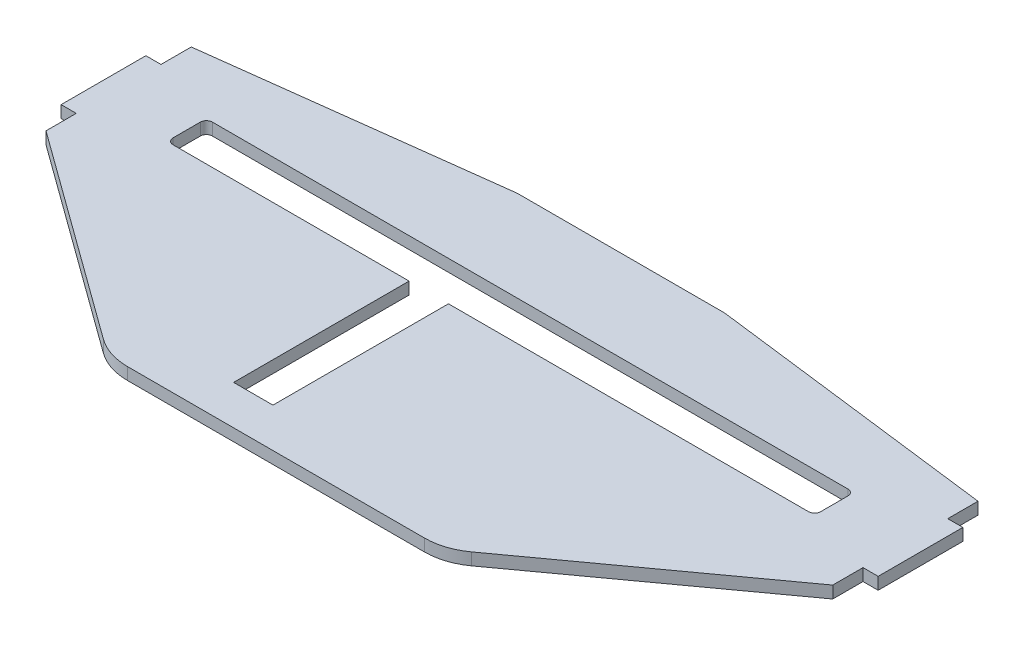
from build123d import *

# Parameters (mm, degrees)
RESSALTO_EXTRUS_O1_DEPTH = 2
CORTE_EXTRUS_O1_DEPTH    = 3


with BuildPart() as part:
    # Esboço1 → Ressalto-extrusão1 (new body)
    with BuildSketch(Plane(origin=(0, 0, 0), x_dir=(1, 0, 0), z_dir=(0, 1, 0))):
        with BuildLine():
            Line((-65, 27.690493718), (-17.774626759, 33.612777476))
            ThreePointArc((-17.774626759, 33.612777476), (-17.153688565, 33.671045747), (-16.530325742, 33.690493718))
            Line((-16.530325742, 33.690493718), (0, 33.690493718))
            Line((0, 33.690493718), (0, -23.309506282))
            Line((0, -23.309506282), (-24.541301383, -23.309506282))
            ThreePointArc((-24.541301383, -23.309506282), (-27.628384162, -22.821073972), (-30.413900746, -21.403490265))
            Line((-30.413900746, -21.403490265), (-65, 3.690493718))
            Line((-65, 3.690493718), (-65, 8.690493718))
            Line((-65, 8.690493718), (-67.5, 8.690493718))
            Line((-67.5, 8.690493718), (-67.5, 22.690493718))
            Line((-67.5, 22.690493718), (-65, 22.690493718))
            Line((-65, 22.690493718), (-65, 27.690493718))
        make_face()
    ressalto_extrus_o1 = extrude(amount=RESSALTO_EXTRUS_O1_DEPTH)

    # Espelhar1: Ressalto-extrusão1 across plane
    add(ressalto_extrus_o1.mirror(Plane(origin=(0, 2, 23.309506282), x_dir=(0, 0, 1), z_dir=(-1, 0, 0))))

    # Esboço2 → Corte-extrusão1 (cut, through all)
    with BuildSketch(Plane(origin=(0, 2, 0), x_dir=(1, 0, 0), z_dir=(0, 1, 0))):
        with BuildLine():
            Line((-52.5, 18.690493718), (52.5, 18.690493718))
            ThreePointArc((52.5, 18.690493718), (53.207106781, 18.397600499), (53.5, 17.690493718))
            Line((53.5, 17.690493718), (53.5, 13.190493718))
            ThreePointArc((53.5, 13.190493718), (53.207106781, 12.483386937), (52.5, 12.190493718))
            Line((52.5, 12.190493718), (-7, 12.190493718))
            Line((-7, 12.190493718), (-7, -16.809506282))
            Line((-7, -16.809506282), (-13.5, -16.809506282))
            Line((-13.5, -16.809506282), (-13.5, 12.190493718))
            Line((-13.5, 12.190493718), (-52.5, 12.190493718))
            ThreePointArc((-52.5, 12.190493718), (-53.207106781, 12.483386937), (-53.5, 13.190493718))
            Line((-53.5, 13.190493718), (-53.5, 17.690493718))
            ThreePointArc((-53.5, 17.690493718), (-53.207106781, 18.397600499), (-52.5, 18.690493718))
        make_face()
    extrude(amount=-CORTE_EXTRUS_O1_DEPTH, mode=Mode.SUBTRACT)


solid = part.part
